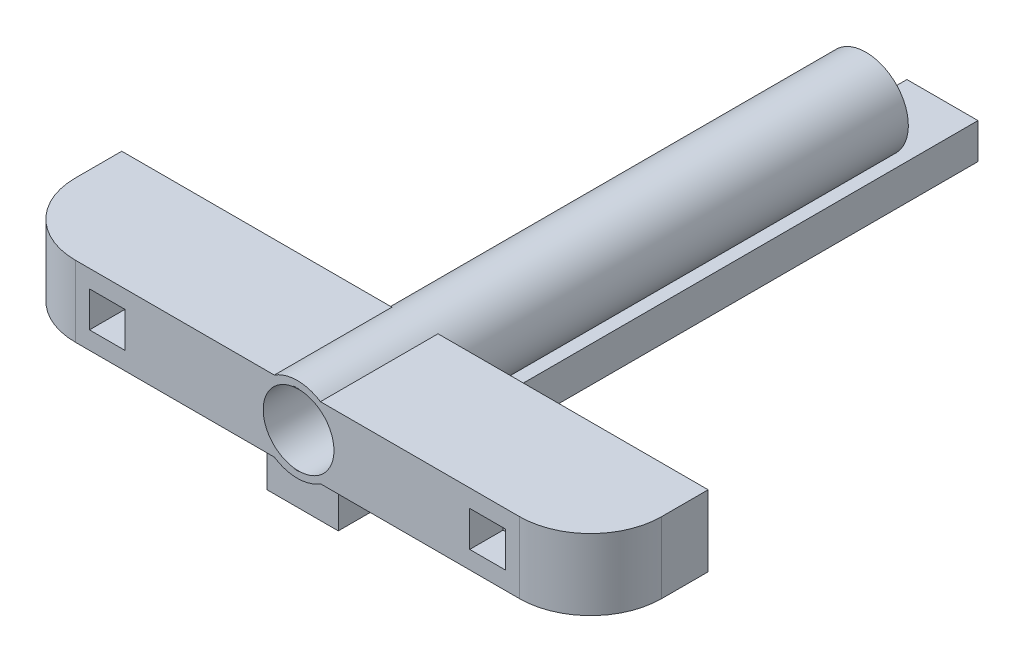
from build123d import *

# Parameters (mm, degrees)
ESQUISSE1_W             = 82.5
ESQUISSE1_H             = 16.543047786
BOSS_EXTRU_1_DEPTH      = 10
CONG_1_R                = 10
ESQUISSE2_W             = 5
ESQUISSE2_H             = 5
ENL_V_MAT_EXTRU_2_DEPTH = 21
ESQUISSE4_W             = 5
ESQUISSE4_H             = 5
ENL_V_MAT_EXTRU_3_DEPTH = 100
ESQUISSE5_R             = 5.960029696
ESQUISSE5_R_2           = 5.029757688
BOSS_EXTRU_4_DEPTH      = 80
ESQUISSE8_R             = 4.979256744
ENL_V_MAT_EXTRU_5_DEPTH = 80
ESQUISSE9_W             = 44.615478915
ESQUISSE9_H             = 9.98536909
BOSS_EXTRU_5_DEPTH      = 10
ESQUISSE10_W            = 10
ESQUISSE10_H            = 10
BOSS_EXTRU_6_DEPTH      = 5
ESQUISSE13_W            = 10
ESQUISSE13_H            = 5
BOSS_EXTRU_7_DEPTH      = 80
ESQUISSE15_R            = 4.979256744
ENL_V_MAT_EXTRU_6_DEPTH = 80


with BuildPart() as part:
    # Esquisse1 → Boss.-Extru.1 (new body)
    with BuildSketch(Plane(origin=(0, 0, 0), x_dir=(1, 0, 0), z_dir=(0, 1, 0))):
        with Locations((-15.683865756, -16.543047786)):
            Rectangle(ESQUISSE1_W, ESQUISSE1_H)
    extrude(amount=BOSS_EXTRU_1_DEPTH)

    # Congé1
    cong_1_edges = [part.edges().sort_by_distance(p)[0] for p in [
        (25.566134244, 5, 24.814571679),
        (-56.933865756, 5, 24.814571679),
    ]]
    fillet(cong_1_edges, radius=CONG_1_R)

    # Esquisse2 → Enlèv. mat.-Extru.2 (cut)
    with BuildSketch(Plane.XY.offset(24.814571679)):
        with Locations((-42.433865756, 5)):
            Rectangle(ESQUISSE2_W, ESQUISSE2_H)
    extrude(amount=-ENL_V_MAT_EXTRU_2_DEPTH, mode=Mode.SUBTRACT)

    # Esquisse4 → Enlèv. mat.-Extru.3 (cut)
    with BuildSketch(Plane.XY.offset(24.814571679)):
        with Locations((11.066134244, 5)):
            Rectangle(ESQUISSE4_W, ESQUISSE4_H)
    extrude(amount=-ENL_V_MAT_EXTRU_3_DEPTH, mode=Mode.SUBTRACT)

    # Esquisse5 → Boss.-Extru.4 (add)
    with BuildSketch(Plane.XY.offset(24.814571679)):
        with Locations((-15.683865756, 5)):
            Circle(ESQUISSE5_R)
        with Locations((-15.683865756, 5)):
            Circle(ESQUISSE5_R_2, mode=Mode.SUBTRACT)
    extrude(amount=-BOSS_EXTRU_4_DEPTH)

    # Esquisse8 → Enlèv. mat.-Extru.5 (cut)
    with BuildSketch(Plane.XY.offset(24.814571679)):
        with Locations((-15.514565948, 5)):
            Circle(ESQUISSE8_R)
    extrude(amount=-ENL_V_MAT_EXTRU_5_DEPTH, mode=Mode.SUBTRACT)

    # Esquisse9 → Boss.-Extru.5 (add)
    with BuildSketch(Plane(origin=(0, 0, 0), x_dir=(1, 0, 0), z_dir=(0, 1, 0))):
        with Locations((-13.028182488, -15.142474607)):
            Rectangle(ESQUISSE9_W, ESQUISSE9_H)
    extrude(amount=BOSS_EXTRU_5_DEPTH)

    # Esquisse10 → Boss.-Extru.6 (add)
    with BuildSketch(Plane(origin=(0, 0, 0), x_dir=(-1, 0, 0), z_dir=(0, -1, 0))):
        with Locations((15.433865756, -19.305846435)):
            Rectangle(ESQUISSE10_W, ESQUISSE10_H)
    extrude(amount=BOSS_EXTRU_6_DEPTH)

    # Esquisse13 → Boss.-Extru.7 (add)
    with BuildSketch(Plane(origin=(0, 0, 14.305846435), x_dir=(-1, 0, 0), z_dir=(0, 0, -1))):
        with Locations((15.433865756, -2.5)):
            Rectangle(ESQUISSE13_W, ESQUISSE13_H)
    extrude(amount=BOSS_EXTRU_7_DEPTH)

    # Esquisse15 → Enlèv. mat.-Extru.6 (cut)
    with BuildSketch(Plane.XY.offset(20.135159152)):
        with Locations((-15.514565948, 5)):
            Circle(ESQUISSE15_R)
    extrude(amount=-ENL_V_MAT_EXTRU_6_DEPTH, mode=Mode.SUBTRACT)


solid = part.part
